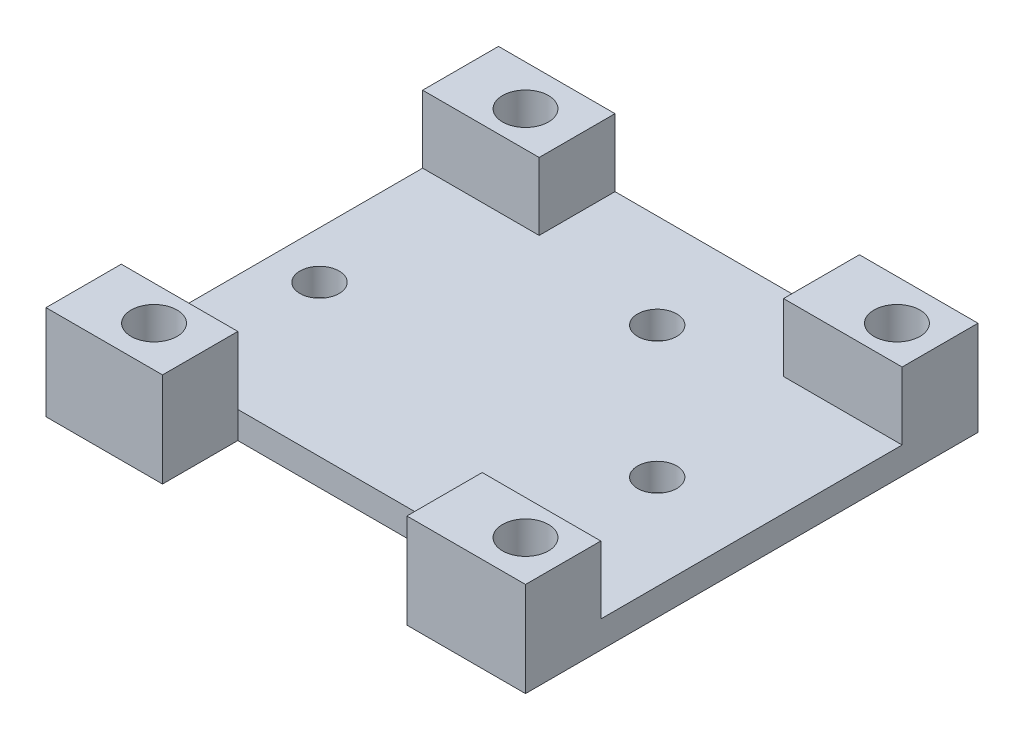
from build123d import *

# Parameters (mm, degrees)
SKETCH1_W              = 40
SKETCH1_H              = 33.5
BOSS_EXTRUDE1_DEPTH    = 7
M3_CLEARANCE_HOLE1_D   = 3.4
SKETCH4_W              = 31.219256934
SKETCH4_H              = 27.926271275
CUT_EXTRUDE1_DEPTH     = 5
SKETCH5_W              = 8.780743066
SKETCH5_H              = 22.309556891
CUT_EXTRUDE2_DEPTH     = 5
M2_5_CLEARANCE_HOLE2_D = 2.9
SKETCH12_W             = 26.872555909
SKETCH12_H             = 5.573728725
CUT_EXTRUDE4_DEPTH     = 8
SKETCH13_W             = 8.780743066
SKETCH13_H             = 5.573728725
BOSS_EXTRUDE2_DEPTH    = 7
SKETCH14_W             = 13.127444091
SKETCH14_H             = 5.616714384
BOSS_EXTRUDE3_DEPTH    = 5
M3_CLEARANCE_HOLE2_D   = 3.4
SKETCH17_W             = 4.5
SKETCH17_H             = 33.5
CUT_EXTRUDE5_DEPTH     = 8


with BuildPart() as part:
    # Sketch1 → Boss-Extrude1 (new body)
    with BuildSketch(Plane(origin=(0, 0, 0), x_dir=(1, 0, 0), z_dir=(0, 1, 0))):
        Rectangle(SKETCH1_W, SKETCH1_H)
    extrude(amount=BOSS_EXTRUDE1_DEPTH)

    # M3 Clearance Hole1 (through all)
    with Locations(Plane(origin=(-10.5, 7, 13.75), x_dir=(0, 0, 1), z_dir=(0, 1, 0))):
        with Locations((0, 0), (-27.5, 27.5)):
            Hole(M3_CLEARANCE_HOLE1_D / 2)

    # Sketch4 → Cut-Extrude1 (cut)
    with BuildSketch(Plane(origin=(0, 7, 0), x_dir=(1, 0, 0), z_dir=(0, 1, 0))):
        with Locations((-4.390371533, 2.786864362)):
            Rectangle(SKETCH4_W, SKETCH4_H)
    extrude(amount=-CUT_EXTRUDE1_DEPTH, mode=Mode.SUBTRACT)

    # Sketch5 → Cut-Extrude2 (cut)
    with BuildSketch(Plane(origin=(0, 7, 0), x_dir=(1, 0, 0), z_dir=(0, 1, 0))):
        with Locations((15.609628467, -0.02149283)):
            Rectangle(SKETCH5_W, SKETCH5_H)
    extrude(amount=-CUT_EXTRUDE2_DEPTH, mode=Mode.SUBTRACT)

    # M2.5 Clearance Hole2 (through all)
    with Locations(Plane(origin=(-12, 2, 0), x_dir=(0, 0, 1), z_dir=(0, 1, 0))):
        with Locations((0, 0), (0, 25), (-9.75, 15.25)):
            Hole(M2_5_CLEARANCE_HOLE2_D / 2)

    # Sketch12 → Cut-Extrude4 (cut, through all)
    with BuildSketch(Plane(origin=(0, 7, 0), x_dir=(1, 0, 0), z_dir=(0, 1, 0))):
        with Locations((6.563722045, -13.963135638)):
            Rectangle(SKETCH12_W, SKETCH12_H)
    extrude(amount=-CUT_EXTRUDE4_DEPTH, mode=Mode.SUBTRACT)

    # Sketch13 → Boss-Extrude2 (add)
    with BuildSketch(Plane.XZ):
        with Locations((15.609628467, 13.963135638)):
            Rectangle(SKETCH13_W, SKETCH13_H)
    extrude(amount=-BOSS_EXTRUDE2_DEPTH)

    # Sketch14 → Boss-Extrude3 (add)
    with BuildSketch(Plane(origin=(0, 2, 0), x_dir=(1, 0, 0), z_dir=(0, 1, 0))):
        with Locations((-13.436277954, 13.941642808)):
            Rectangle(SKETCH14_W, SKETCH14_H)
    extrude(amount=BOSS_EXTRUDE3_DEPTH)

    # M3 Clearance Hole2 (through all)
    with Locations(Plane(origin=(0, 7, 0), x_dir=(1, 0, 0), z_dir=(0, 1, 0))):
        with Locations((-10.5, 13.75), (17, -13.75)):
            Hole(M3_CLEARANCE_HOLE2_D / 2)

    # Sketch17 → Cut-Extrude5 (cut, through all)
    with BuildSketch(Plane(origin=(0, 7, 0), x_dir=(1, 0, 0), z_dir=(0, 1, 0))):
        with Locations((-17.75, 0)):
            Rectangle(SKETCH17_W, SKETCH17_H)
    extrude(amount=-CUT_EXTRUDE5_DEPTH, mode=Mode.SUBTRACT)


solid = part.part
